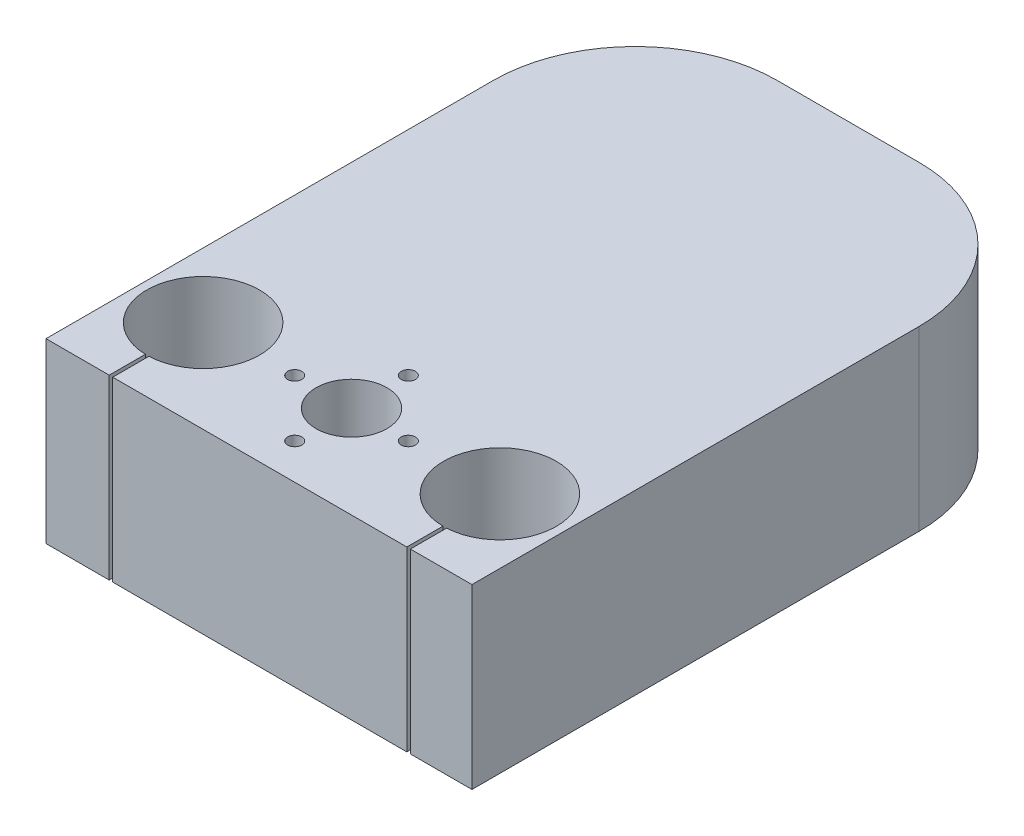
from build123d import *

# Parameters (mm, degrees)
SKETCH1_W           = 60
SKETCH1_H           = 80
BOSS_EXTRUDE1_DEPTH = 25
FILLET1_R           = 20
SKETCH3_R           = 7.95
CUT_EXTRUDE2_DEPTH  = 35
SKETCH5_W           = 60
SKETCH5_H           = 25
BOSS_EXTRUDE2_DEPTH = 3
SKETCH6_R           = 5
SKETCH6_R_2         = 1
CUT_EXTRUDE3_DEPTH  = 26
SKETCH7_R           = 2.5
CUT_EXTRUDE4_DEPTH  = 15
SKETCH8_W           = 0.5
SKETCH8_H           = 1.458969306
SKETCH8_H_2         = 7.530561822
CUT_EXTRUDE5_DEPTH  = 26


with BuildPart() as part:
    # Sketch1 → Boss-Extrude1 (new body)
    with BuildSketch(Plane(origin=(0, 0, 0), x_dir=(1, 0, 0), z_dir=(0, 1, 0))):
        Rectangle(SKETCH1_W, SKETCH1_H)
    extrude(amount=BOSS_EXTRUDE1_DEPTH)

    # Fillet1
    fillet1_edges = [part.edges().sort_by_distance(p)[0] for p in [
        (-30, 12.5, -40),
        (30, 12.5, -40),
    ]]
    fillet(fillet1_edges, radius=FILLET1_R)

    # Sketch3 → Cut-Extrude2 (cut)
    with BuildSketch(Plane(origin=(0, 25, 0), x_dir=(1, 0, 0), z_dir=(0, 1, 0))):
        with Locations((-20.9, -29.964854959)):
            Circle(SKETCH3_R)
        with Locations((20.9, -29.964854959)):
            Circle(SKETCH3_R)
    extrude(amount=-CUT_EXTRUDE2_DEPTH, mode=Mode.SUBTRACT)

    # Sketch5 → Boss-Extrude2 (add)
    with BuildSketch(Plane.XY.offset(40)):
        with Locations((0, 12.5)):
            Rectangle(SKETCH5_W, SKETCH5_H)
    extrude(amount=BOSS_EXTRUDE2_DEPTH)

    # Sketch6 → Cut-Extrude3 (cut, through all)
    with BuildSketch(Plane(origin=(0, 25, 0), x_dir=(1, 0, 0), z_dir=(0, 1, 0))):
        with Locations((0, -29.964854959)):
            Circle(SKETCH6_R)
        with Locations((0, -37.964854959)):
            Circle(SKETCH6_R_2)
        with Locations((8, -29.964854959)):
            Circle(SKETCH6_R_2)
        with Locations((0, -21.964854959)):
            Circle(SKETCH6_R_2)
        with Locations((-8, -29.964854959)):
            Circle(SKETCH6_R_2)
    extrude(amount=-CUT_EXTRUDE3_DEPTH, mode=Mode.SUBTRACT)

    # Sketch7 → Cut-Extrude4 (cut)
    with BuildSketch(Plane(origin=(0, 0, 0), x_dir=(-1, 0, 0), z_dir=(0, -1, 0))):
        with Locations((-0.26141162, 23.519285142)):
            Circle(SKETCH7_R)
    extrude(amount=-CUT_EXTRUDE4_DEPTH, mode=Mode.SUBTRACT)

    # Sketch8 → Cut-Extrude5 (cut, through all)
    with BuildSketch(Plane.XZ):
        with BuildLine():
            ThreePointArc((20.828077187, 37.914529614), (21.078165346, 37.9128583), (21.328077187, 37.903321431))
            Line((21.328077187, 37.903321431), (21.328077187, 43))
            Line((21.328077187, 43), (20.828077187, 43))
            Line((20.828077187, 43), (20.828077187, 37.914529614))
        make_face()
        with Locations((21.078077187, 43.729484653)):
            Rectangle(SKETCH8_W, SKETCH8_H)
        with BuildLine():
            Line((21.328077187, 37.903321431), (21.328077187, 36.928407484))
            Line((21.328077187, 36.928407484), (20.828077187, 36.928407484))
            Line((20.828077187, 36.928407484), (20.828077187, 37.914529614))
            ThreePointArc((20.828077187, 37.914529614), (15.303987418, 24.317984748), (28.85, 29.964854959))
            ThreePointArc((28.85, 29.964854959), (26.670862745, 35.432911578), (21.328077187, 37.903321431))
        make_face()
        with BuildLine():
            Line((20.828077187, 36.928407484), (21.328077187, 36.928407484))
            Line((21.328077187, 36.928407484), (21.328077187, 37.903321431))
            ThreePointArc((21.328077187, 37.903321431), (21.078165346, 37.9128583), (20.828077187, 37.914529614))
            Line((20.828077187, 37.914529614), (20.828077187, 36.928407484))
        make_face()
        with Locations((-20.848704866, 40.693688395)):
            Rectangle(SKETCH8_W, SKETCH8_H_2)
    extrude(amount=-CUT_EXTRUDE5_DEPTH, mode=Mode.SUBTRACT)


solid = part.part
